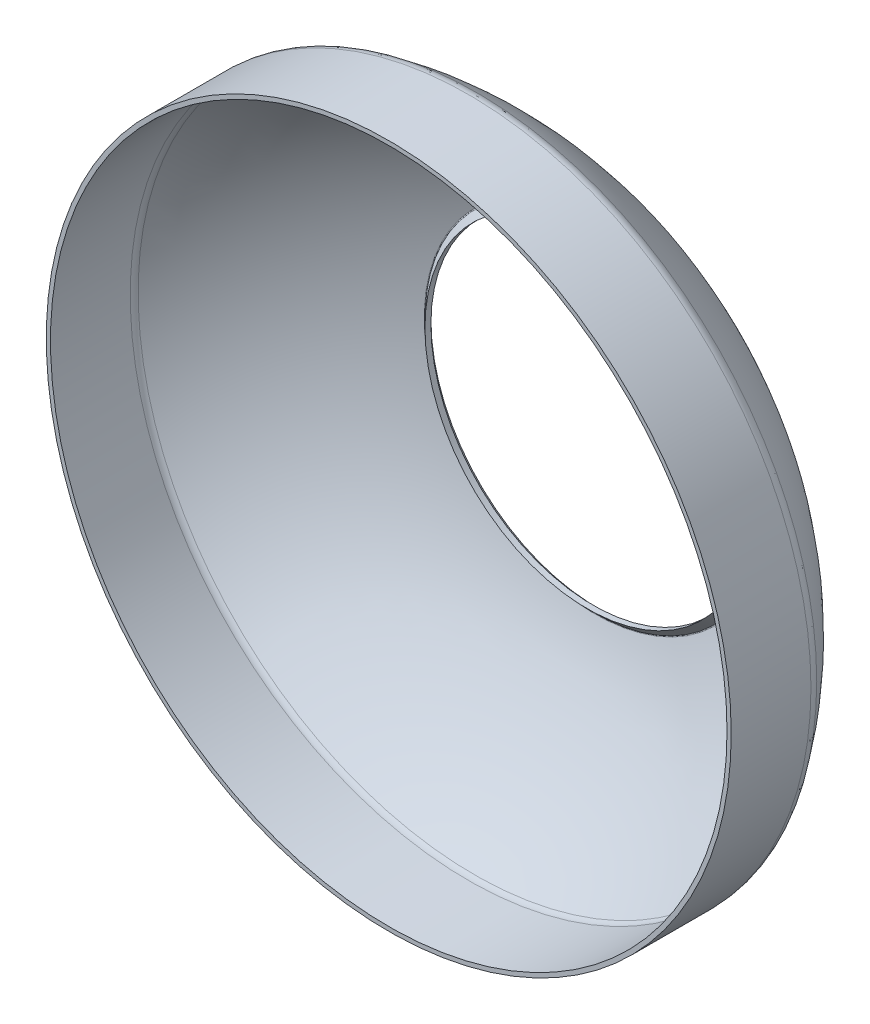
from build123d import *


with BuildPart() as part:
    # Skica1 → Rotovat1 (revolve)
    with BuildSketch(Plane(origin=(0, 0, 0), x_dir=(1, 0, 0), z_dir=(0, 1, 0)), mode=Mode.PRIVATE) as rotovat1_sk:
        with BuildLine():
            Line((-32.5, 0), (-32.5, 7.565103942))
            ThreePointArc((-32.5, 7.565103942), (-32.435408582, 7.985441804), (-32.247594402, 8.36699364))
            ThreePointArc((-32.247594402, 8.36699364), (-25.24241357, 15.48854184), (-16.287341368, 19.915243672))
            ThreePointArc((-16.287341368, 19.915243672), (-16.02134619, 19.921234959), (-15.789937051, 19.789937051))
            Line((-15.789937051, 19.789937051), (-15.4, 19.4))
            Line((-15.4, 19.4), (-15.4, 18.834314575))
            Line((-15.4, 18.834314575), (-16.072779763, 19.507094338))
            ThreePointArc((-16.072779763, 19.507094338), (-16.119061591, 19.53335392), (-16.172260627, 19.532155663))
            ThreePointArc((-16.172260627, 19.532155663), (-25.007931866, 15.164476522), (-31.919710287, 8.137882298))
            ThreePointArc((-31.919710287, 8.137882298), (-32.053863273, 7.865345272), (-32.1, 7.565103942))
            Line((-32.1, 7.565103942), (-32.1, 0))
            Line((-32.1, 0), (-32.5, 0))
        make_face()
    revolve(rotovat1_sk.sketch.rotate(Axis((0, 0, 0), (0, 0, -1)), 180), axis=Axis((0, 0, 0), (0, 0, -1)))  # turned: the seam where the file's is


solid = part.part
